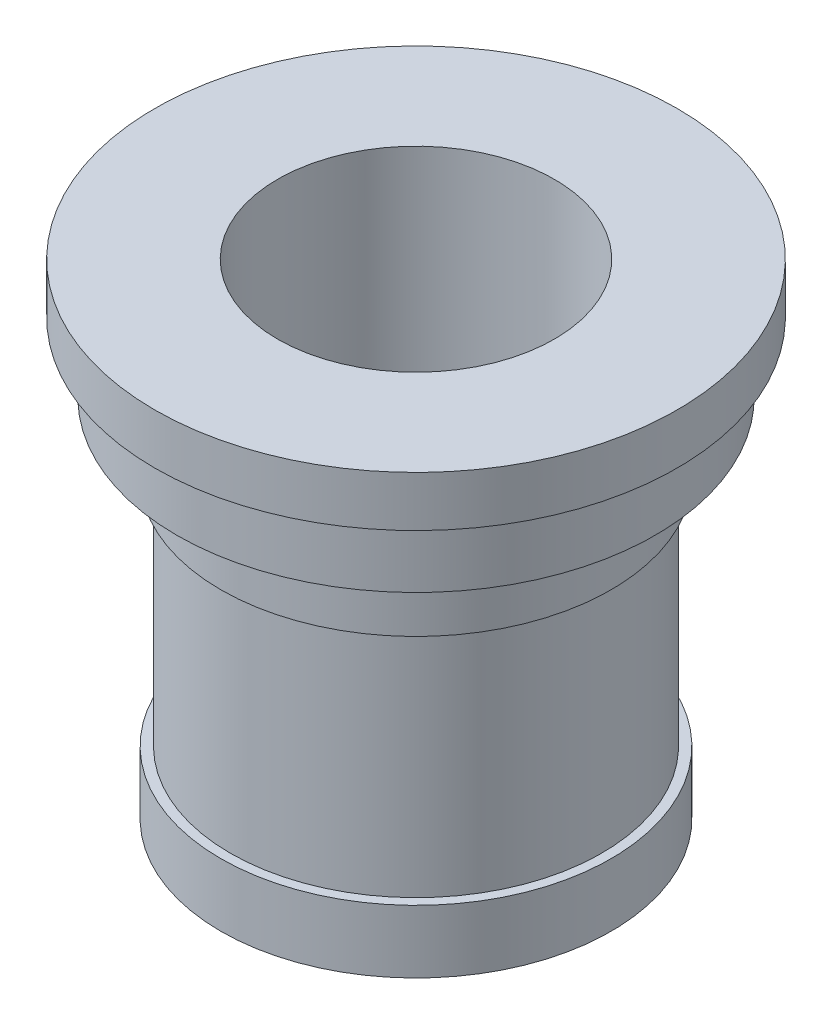
from build123d import *

# Parameters (mm, degrees)
SKETCH3_R          = 1.5
CUT_EXTRUDE1_DEPTH = 5


with BuildPart() as part:
    # Sketch1 → Revolve1 (revolve)
    with BuildSketch(Plane.XY, mode=Mode.PRIVATE) as revolve1_sk:
        Polygon((22, 0), (22, 77), (41.5, 77), (41.5, 69), (38, 69), (38, 58), (31, 58), (31, 47), (29.5, 47), (29.5, 10), (31, 10), (31, 0), align=None)
    revolve(revolve1_sk.sketch.rotate(Axis((0, 42.013888889, 0), (0, -1, 0)), 90), axis=Axis((0, 42.013888889, 0), (0, -1, 0)))  # turned: the seam where the file's is

    # Sketch3 → Cut-Extrude1 (cut)
    with BuildSketch(Plane.XZ):
        with Locations((-22, 0)):
            Circle(SKETCH3_R)
    extrude(amount=-CUT_EXTRUDE1_DEPTH, mode=Mode.SUBTRACT)


solid = part.part
